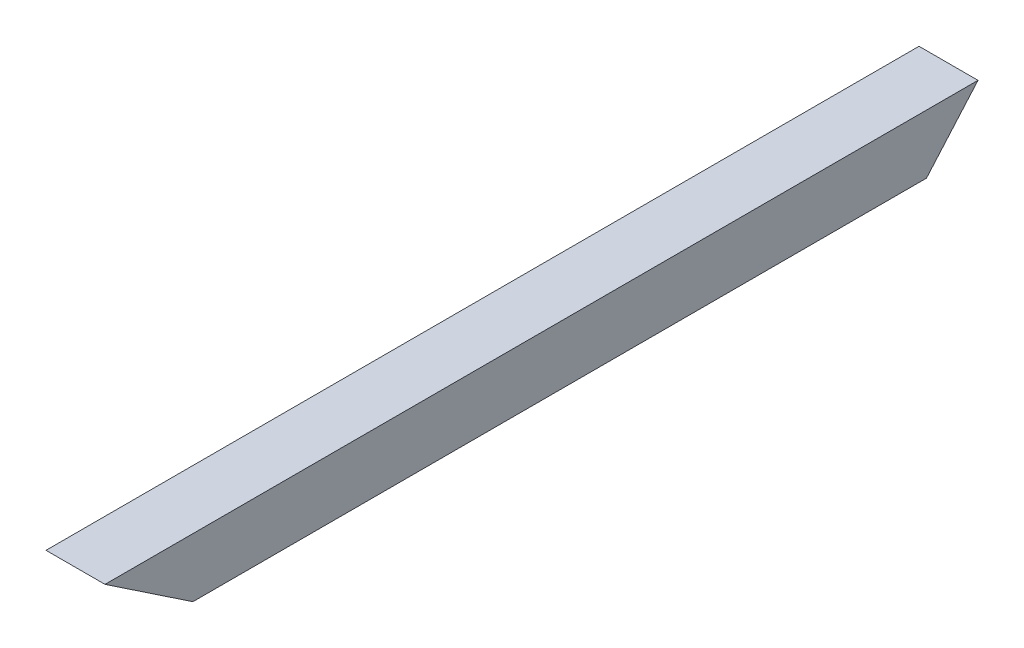
from build123d import *

# Parameters (mm, degrees)
SKETCH1_W           = 25.4
SKETCH1_H           = 25.4
SKETCH1_W_2         = 22.098
SKETCH1_H_2         = 22.098
BOSS_EXTRUDE1_DEPTH = 378.309163
CUT_EXTRUDE2_DEPTH  = 26.4
SKETCH5_W           = 25.4
SKETCH5_H           = 25.4
CUT_EXTRUDE3_DEPTH  = 244.121498097


with BuildPart() as part:
    # Sketch1 → Boss-Extrude1 (new body)
    with BuildSketch(Plane.XY):
        Rectangle(SKETCH1_W, SKETCH1_H)
        Rectangle(SKETCH1_W_2, SKETCH1_H_2, mode=Mode.SUBTRACT)
    extrude(amount=BOSS_EXTRUDE1_DEPTH)

    # Sketch4 → Cut-Extrude2 (cut, through all)
    with BuildSketch(Plane.ZY.offset(12.7)):
        Polygon((0, 12.7), (22.23162961, -12.749147595), (0, -16.391086304), align=None)
    extrude(amount=-CUT_EXTRUDE2_DEPTH, mode=Mode.SUBTRACT)

    # Sketch5 → Cut-Extrude3 (cut, through all)
    with BuildSketch(Plane(origin=(0, -132.21706056, 182.766862758), x_dir=(1, 0, 0), z_dir=(0, 0.557172611, 0.830396701))):
        Rectangle(SKETCH5_W, SKETCH5_H)
    extrude(amount=CUT_EXTRUDE3_DEPTH, mode=Mode.SUBTRACT)


solid = part.part
